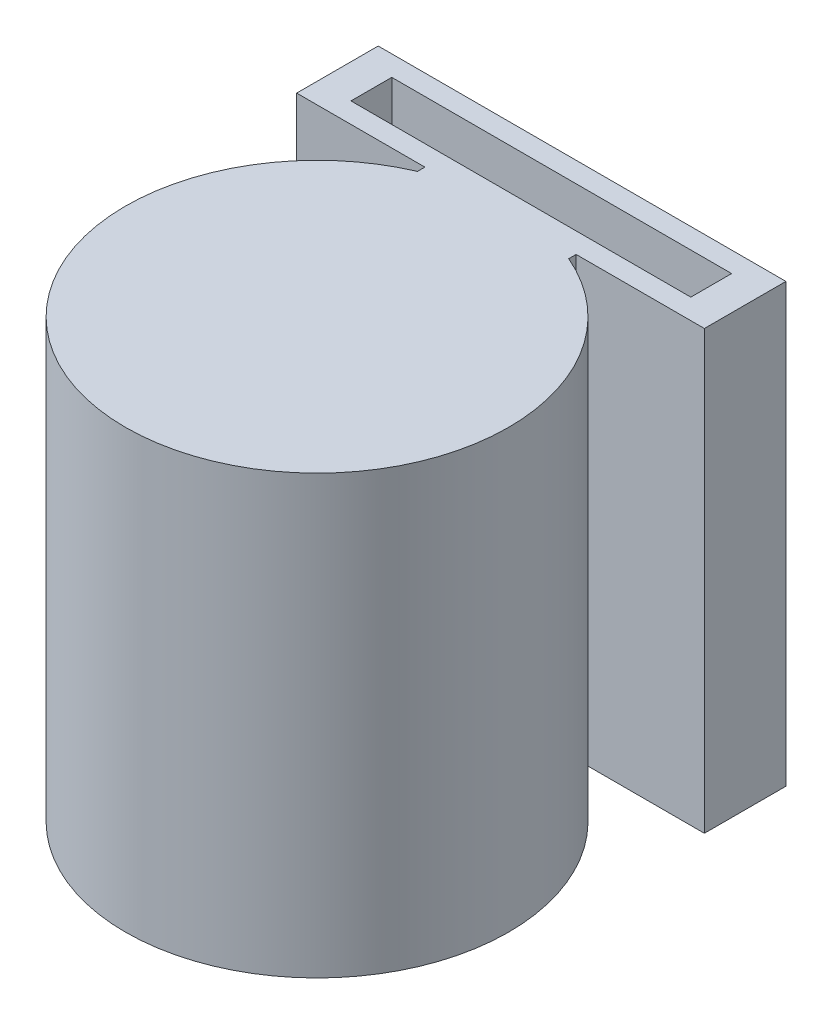
from build123d import *

# Parameters (mm, degrees)
CROQUIS1_W                 = 30
CROQUIS1_H                 = 6
CROQUIS1_W_2               = 25.006000518
CROQUIS1_H_2               = 3.004001618
SALIENTE_EXTRUIR1_DEPTH    = 32.17
CROQUIS2_W                 = 25
CROQUIS2_H                 = 25.003841724
CORTAR_EXTRUIR1_DEPTH      = 1.497999
CROQUIS3_R                 = 14.098435913
CROQUIS3_R_2               = 13.1
SALIENTE_EXTRUIR2_DEPTH    = 32.17
CROQUIS10_W                = 30.177827817
CROQUIS10_H                = 41.273822818
SALIENTE_EXTRUIR4_DEPTH    = 22
CORTAR_EXTRUIR2_DEPTH      = 10
CORTAR_EXTRUIR2_DEPTH_BACK = 58
CROQUIS12_W                = 43.091208183
CROQUIS12_H                = 18.563452801
CORTAR_EXTRUIR3_DEPTH      = 58
CORTAR_EXTRUIR3_DEPTH_BACK = 58
SALIENTE_EXTRUIR6_DEPTH    = 32.17
CROQUIS22_R                = 5
CORTAR_EXTRUIR6_DEPTH      = 4


with BuildPart() as part:
    # Croquis1 → Saliente-Extruir1 (new body)
    with BuildSketch(Plane(origin=(0, 0, 0), x_dir=(1, 0, 0), z_dir=(0, 1, 0))):
        with Locations((0, 25)):
            Rectangle(CROQUIS1_W, CROQUIS1_H)
        with Locations((0, 25)):
            Rectangle(CROQUIS1_W_2, CROQUIS1_H_2, mode=Mode.SUBTRACT)
    extrude(amount=-SALIENTE_EXTRUIR1_DEPTH)

    # Croquis2 → Cortar-Extruir1 (cut)
    with BuildSketch(Plane(origin=(0, 0, -28), x_dir=(1, 0, 0), z_dir=(0, 0, -1))):
        with Locations((0, 17.668079138)):
            Rectangle(CROQUIS2_W, CROQUIS2_H)
    extrude(amount=-CORTAR_EXTRUIR1_DEPTH, mode=Mode.SUBTRACT)

    # Croquis3 → Saliente-Extruir2 (add)
    with BuildSketch(Plane(origin=(0, 0, 0), x_dir=(1, 0, 0), z_dir=(0, 1, 0))):
        with Locations((0, 8.499687815)):
            Circle(CROQUIS3_R)
        with Locations((0, 8.499687815)):
            Circle(CROQUIS3_R_2, mode=Mode.SUBTRACT)
    extrude(amount=-SALIENTE_EXTRUIR2_DEPTH)

    # Croquis10 → Saliente-Extruir4 (add)
    with BuildSketch(Plane(origin=(0, -11, -11), x_dir=(-1, 0, 0), z_dir=(0, -0.707106781, -0.707106781))):
        with Locations((-0.620676422, -5.363625683)):
            Rectangle(CROQUIS10_W, CROQUIS10_H)
    extrude(amount=-SALIENTE_EXTRUIR4_DEPTH)

    # Croquis11 → Cortar-Extruir2 (cut, two sides)
    with BuildSketch(Plane.XZ.offset(32.17)) as cortar_extruir2_sk:
        with BuildLine():
            Line((-4.676723545, -21.799843908), (-14.468237486, -21.799843908))
            Line((-14.468237486, -21.799843908), (-14.468237486, 22.941505279))
            Line((-14.468237486, 22.941505279), (15.709590331, 22.941505279))
            Line((15.709590331, 22.941505279), (15.709590331, -21.799843908))
            Line((15.709590331, -21.799843908), (4.676723545, -21.799843908))
            ThreePointArc((4.676723545, -21.799843908), (0, 5.598748098), (-4.676723545, -21.799843908))
        make_face()
    extrude(amount=CORTAR_EXTRUIR2_DEPTH, mode=Mode.SUBTRACT)
    extrude(cortar_extruir2_sk.sketch, amount=-CORTAR_EXTRUIR2_DEPTH_BACK, mode=Mode.SUBTRACT)

    # Croquis12 → Cortar-Extruir3 (cut, two sides)
    with BuildSketch(Plane(origin=(0, 0, 0), x_dir=(0, 0, -1), z_dir=(1, 0, 0))) as cortar_extruir3_sk:
        with Locations((6.454395908, 9.281726401)):
            Rectangle(CROQUIS12_W, CROQUIS12_H)
    extrude(amount=CORTAR_EXTRUIR3_DEPTH, mode=Mode.SUBTRACT)
    extrude(cortar_extruir3_sk.sketch, amount=-CORTAR_EXTRUIR3_DEPTH_BACK, mode=Mode.SUBTRACT)

    # Croquis23 → Saliente-Extruir6 (add, through all)
    with BuildSketch(Plane(origin=(0, 0, 0), x_dir=(1, 0, 0), z_dir=(0, 1, 0))):
        with BuildLine():
            Line((-5.562938112, 22), (-4.062938112, 22))
            ThreePointArc((-4.062938112, 22), (-4.820668551, 21.748350009), (-5.562938112, 21.454208831))
            Line((-5.562938112, 21.454208831), (-5.562938112, 22))
        make_face()
        with BuildLine():
            Line((4.062938112, 22), (5.562938112, 22))
            Line((5.562938112, 22), (5.562938112, 21.454208831))
            ThreePointArc((5.562938112, 21.454208831), (4.820668551, 21.748350009), (4.062938112, 22))
        make_face()
    extrude(amount=-SALIENTE_EXTRUIR6_DEPTH)

    # Croquis22 → Cortar-Extruir6 (cut)
    with BuildSketch(Plane.XY.offset(-23.497999191)):
        with Locations((0, -17.33)):
            Circle(CROQUIS22_R)
    extrude(amount=CORTAR_EXTRUIR6_DEPTH, mode=Mode.SUBTRACT)


solid = part.part
